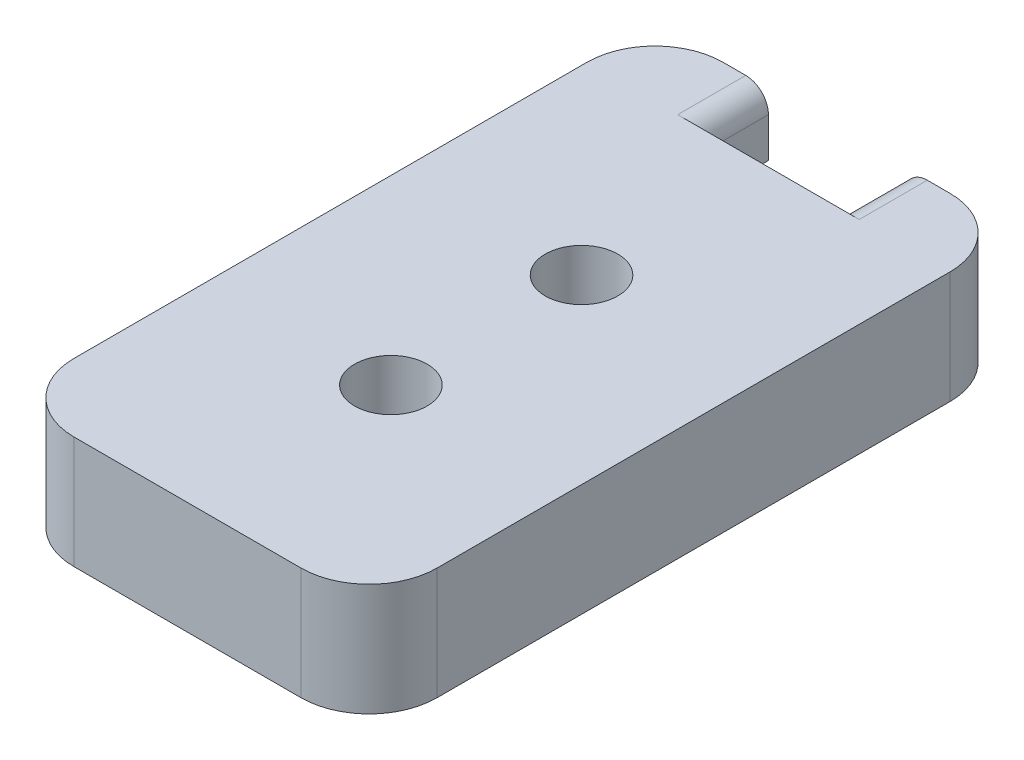
from build123d import *

# Parameters (mm, degrees)
SKETCH_2_W          = 20
SKETCH_2_H          = 4.95
EXTRUDE_1_DEPTH     = 25.6
SKETCH_3_R          = 1.6
CUT_EXTRUDE_1_DEPTH = 5.95
SKETCH_4_W          = 20
SKETCH_4_H          = 4.95
EXTRUDE_2_DEPTH     = 3
CUT_EXTRUDE_2_DEPTH = 3
SKETCH_6_R          = 0.25
CUT_EXTRUDE_3_DEPTH = 3
FILLET_2_R          = 1
SKETCH_7_W          = 2
SKETCH_7_H          = 4.95
CUT_EXTRUDE_4_DEPTH = 29.6
FILLET_3_R          = 3


with BuildPart() as part:
    # 草图2 → 凸台-拉伸1 (new body)
    with BuildSketch(Plane.XY):
        with Locations((10, -2.475)):
            Rectangle(SKETCH_2_W, SKETCH_2_H)
    extrude(amount=EXTRUDE_1_DEPTH)

    # 草图3 → 切除-拉伸1 (cut, through all)
    with BuildSketch(Plane(origin=(0, 0, 0), x_dir=(1, 0, 0), z_dir=(0, 1, 0))):
        with Locations((10, -8.236740591)):
            Circle(SKETCH_3_R)
        with Locations((10, -16.636740591)):
            Circle(SKETCH_3_R)
    extrude(amount=-CUT_EXTRUDE_1_DEPTH, mode=Mode.SUBTRACT)

    # 草图4 → 凸台-拉伸2 (add)
    with BuildSketch(Plane(origin=(0, 0, 0), x_dir=(-1, 0, 0), z_dir=(0, 0, -1))):
        with Locations((-10, -2.475)):
            Rectangle(SKETCH_4_W, SKETCH_4_H)
    extrude(amount=EXTRUDE_2_DEPTH)

    # 草图5 → 切除-拉伸2 (cut)
    with BuildSketch(Plane(origin=(0, 0, -3), x_dir=(-1, 0, 0), z_dir=(0, 0, -1))):
        Polygon((-10, 0), (-7, 0), (-7, -3), (-13, -3), (-13, 0), align=None)
    extrude(amount=-CUT_EXTRUDE_2_DEPTH, mode=Mode.SUBTRACT)

    # 草图6 → 切除-拉伸3 (cut)
    with BuildSketch(Plane(origin=(0, 0, -3), x_dir=(-1, 0, 0), z_dir=(0, 0, -1))):
        with Locations((-7, -3)):
            Circle(SKETCH_6_R)
        with Locations((-13, -3)):
            Circle(SKETCH_6_R)
    extrude(amount=-CUT_EXTRUDE_3_DEPTH, mode=Mode.SUBTRACT)

    # 圆角2
    fillet_2_edges = [part.edges().sort_by_distance(p)[0] for p in [
        (13, 0, -1.5),
        (7, 0, -1.5),
    ]]
    fillet(fillet_2_edges, radius=FILLET_2_R)

    # 草图7 → 切除-拉伸4 (cut, through all)
    with BuildSketch(Plane(origin=(0, 0, -3), x_dir=(-1, 0, 0), z_dir=(0, 0, -1))):
        with Locations((-1, -2.475)):
            Rectangle(SKETCH_7_W, SKETCH_7_H)
        with Locations((-19, -2.475)):
            Rectangle(SKETCH_7_W, SKETCH_7_H)
    extrude(amount=-CUT_EXTRUDE_4_DEPTH, mode=Mode.SUBTRACT)

    # 圆角3
    fillet_3_edges = [part.edges().sort_by_distance(p)[0] for p in [
        (2, -2.475, 25.6),
        (2, -2.475, -3),
        (18, -2.475, 25.6),
        (18, -2.475, -3),
    ]]
    fillet(fillet_3_edges, radius=FILLET_3_R)


solid = part.part
